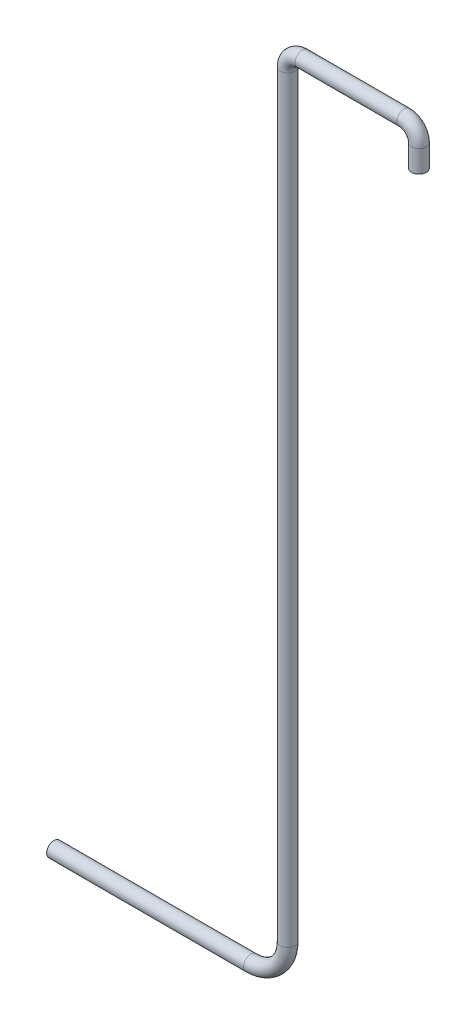
from build123d import *

# Parameters (mm, degrees)
ESQUISSE2_R = 0.1


with BuildPart() as part:
    # Balayage1: sweep along a path in Esquisse1
    with BuildLine(Plane.XY) as balayage1_path:
        Line((0, 0), (0, 0.3))
        ThreePointArc((0, 0.3), (-0.058578644, 0.441421356), (-0.2, 0.5))
        Line((-0.2, 0.5), (-1.584533741, 0.5))
        ThreePointArc((-1.584533741, 0.5), (-1.725955098, 0.441421356), (-1.784533741, 0.3))
        Line((-1.784533741, 0.3), (-1.784533741, -9.992430607))
        ThreePointArc((-1.784533741, -9.992430607), (-1.930980351, -10.345983998), (-2.284533741, -10.492430607))
        Line((-2.284533741, -10.492430607), (-4.960200575, -10.492430607))
    # Esquisse2 → Balayage1 (sweep)
    with BuildSketch(Plane(origin=(0, 0, 0), x_dir=(1, 0, 0), z_dir=(0, 1, 0))):
        Circle(ESQUISSE2_R)
    sweep(path=balayage1_path.line)


solid = part.part
